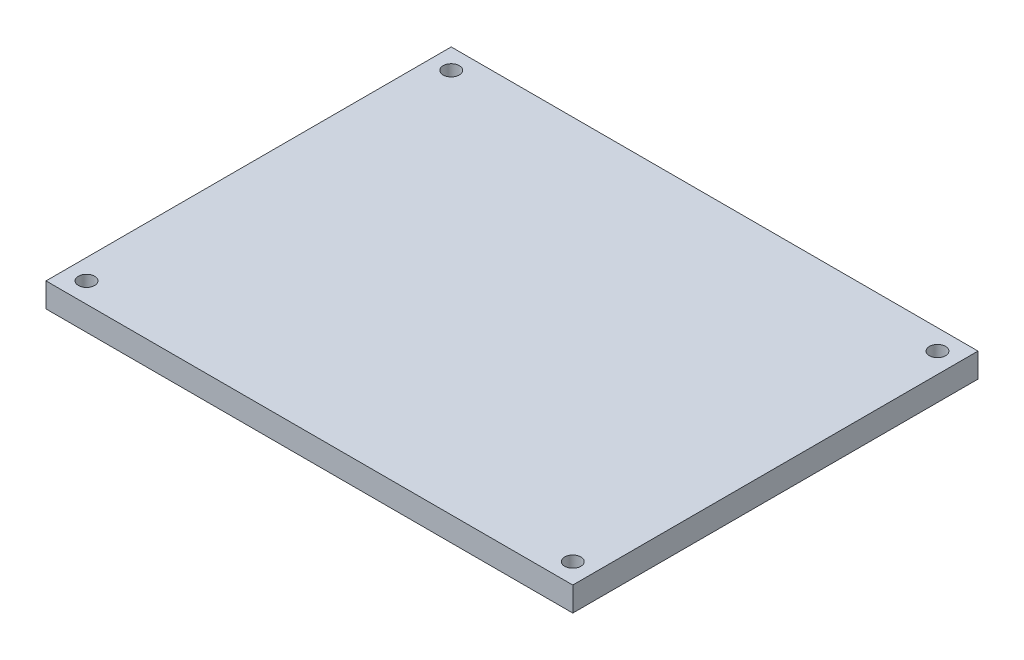
from build123d import *

# Parameters (mm, degrees)
SKETCH1_W           = 130
SKETCH1_H           = 100
BOSS_EXTRUDE1_DEPTH = 6
SKETCH3_R           = 2
CUT_EXTRUDE1_DEPTH  = 7


with BuildPart() as part:
    # Sketch1 → Boss-Extrude1 (new body)
    with BuildSketch(Plane(origin=(0, 0, 0), x_dir=(1, 0, 0), z_dir=(0, 1, 0))):
        Rectangle(SKETCH1_W, SKETCH1_H)
    extrude(amount=BOSS_EXTRUDE1_DEPTH)

    # Sketch3 → Cut-Extrude1 (cut, through all)
    with BuildSketch(Plane(origin=(0, 6, 0), x_dir=(1, 0, 0), z_dir=(0, 1, 0))):
        with Locations((-60, 45)):
            Circle(SKETCH3_R)
        with Locations((-60, -45)):
            Circle(SKETCH3_R)
        with Locations((60, -45)):
            Circle(SKETCH3_R)
        with Locations((60, 45)):
            Circle(SKETCH3_R)
    extrude(amount=-CUT_EXTRUDE1_DEPTH, mode=Mode.SUBTRACT)


solid = part.part
